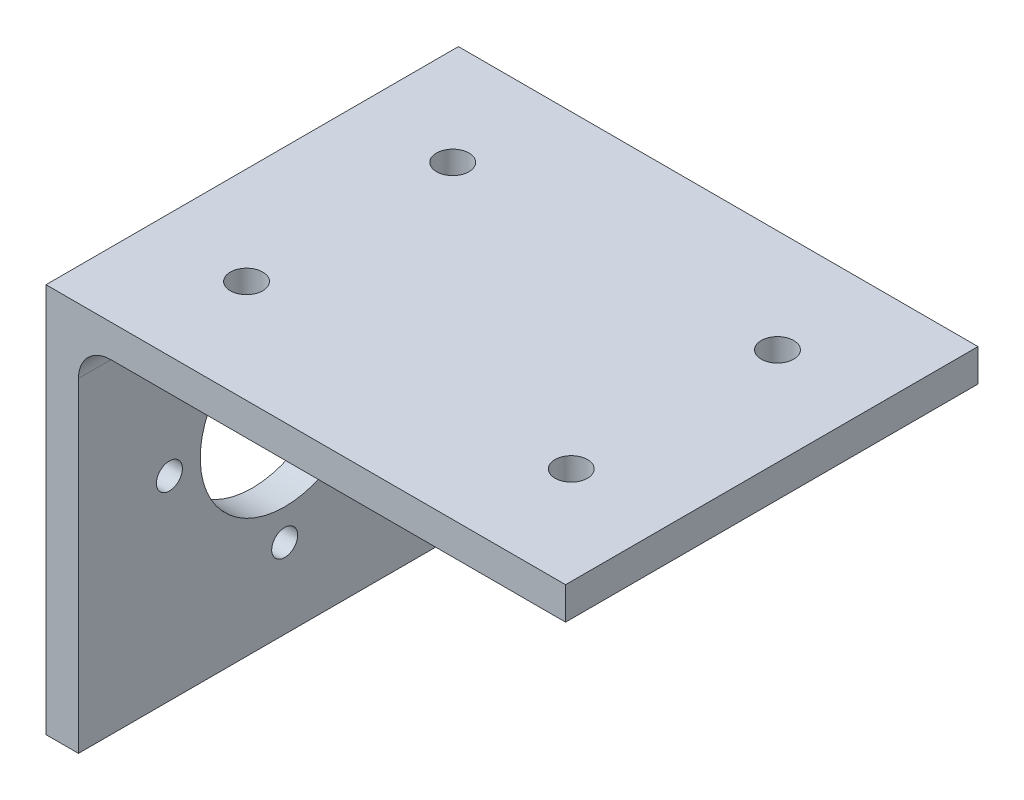
from build123d import *

# Parameters (mm, degrees)
BOSS_EXTRUDE1_DEPTH = 63.5
SKETCH2_R           = 13
SKETCH2_R_2         = 2
CUT_EXTRUDE1_DEPTH  = 5
SKETCH3_R           = 2.5
CUT_EXTRUDE2_DEPTH  = 5


with BuildPart() as part:
    # Sketch1 → Boss-Extrude1 (new body)
    with BuildSketch(Plane.XY):
        with BuildLine():
            Line((0, 0), (0, 60))
            Line((0, 60), (80, 60))
            Line((80, 60), (80, 55))
            Line((80, 55), (10, 55))
            ThreePointArc((10, 55), (6.464466094, 53.535533906), (5, 50))
            Line((5, 50), (5, 0))
            Line((5, 0), (0, 0))
        make_face()
    extrude(amount=BOSS_EXTRUDE1_DEPTH)

    # Sketch2 → Cut-Extrude1 (cut)
    with BuildSketch(Plane.ZY):
        with Locations((31.75, 30)):
            Circle(SKETCH2_R)
        with Locations((49.5, 30)):
            Circle(SKETCH2_R_2)
        with Locations((31.75, 12.25)):
            Circle(SKETCH2_R_2)
        with Locations((14, 30)):
            Circle(SKETCH2_R_2)
        with Locations((31.75, 47.75)):
            Circle(SKETCH2_R_2)
    extrude(amount=-CUT_EXTRUDE1_DEPTH, mode=Mode.SUBTRACT)

    # Sketch3 → Cut-Extrude2 (cut)
    with BuildSketch(Plane(origin=(0, 60, 0), x_dir=(1, 0, 0), z_dir=(0, 1, 0))):
        with Locations((15, -15.875)):
            Circle(SKETCH3_R)
        with Locations((65, -15.875)):
            Circle(SKETCH3_R)
        with Locations((65, -47.625)):
            Circle(SKETCH3_R)
        with Locations((15, -47.625)):
            Circle(SKETCH3_R)
    extrude(amount=-CUT_EXTRUDE2_DEPTH, mode=Mode.SUBTRACT)


solid = part.part
